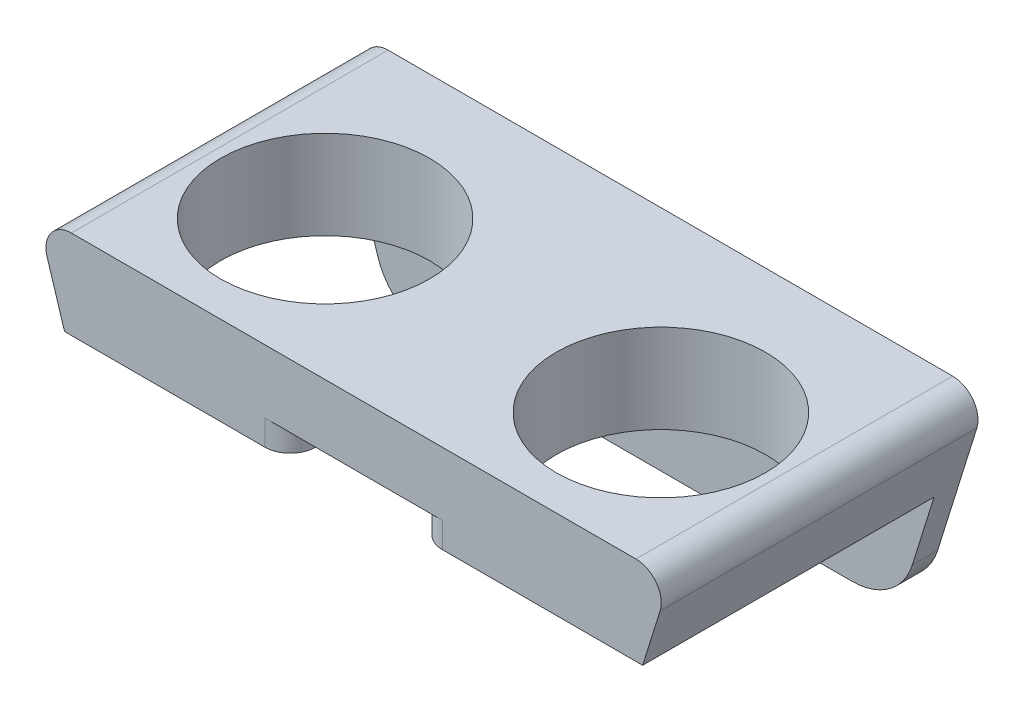
from build123d import *

# Parameters (mm, degrees)
SKETCH1_W               = 50
SKETCH1_H               = 24
SKETCH1_R               = 8.25
BOSS_EXTRUDE1_DEPTH     = 7
SKETCH2_W               = 12.5
SKETCH2_H               = 4.5
CUT_EXTRUDE1_DEPTH      = 4.022504106
SKETCH3_W               = 50
SKETCH3_H               = 16
SKETCH3_R               = 1.55
BOSS_EXTRUDE2_DEPTH     = 2
CUT_EXTRUDE2_DEPTH      = 25
CUT_EXTRUDE2_DEPTH_BACK = 3
FILLET1_R               = 5
FILLET2_R               = 2
SKETCH5_W               = 57.1125727
SKETCH5_H               = 23.157416517
CUT_EXTRUDE3_DEPTH      = 1
SKETCH6_W               = 10
SKETCH6_H               = 4
CUT_EXTRUDE4_DEPTH      = 2
FILLET3_R               = 1
FILLET4_R               = 2


with BuildPart() as part:
    # Sketch1 → Boss-Extrude1 (new body)
    with BuildSketch(Plane(origin=(0, 0, 0), x_dir=(1, 0, 0), z_dir=(0, 1, 0))):
        with Locations((-25, 12)):
            Rectangle(SKETCH1_W, SKETCH1_H)
        with Locations((-38.25, 12)):
            Circle(SKETCH1_R, mode=Mode.SUBTRACT)
        with Locations((-11.75, 12)):
            Circle(SKETCH1_R, mode=Mode.SUBTRACT)
    extrude(amount=BOSS_EXTRUDE1_DEPTH)

    # Sketch2 → Cut-Extrude1 (cut)
    with BuildSketch(Plane.XZ):
        with Locations((-25, -19.75)):
            Rectangle(SKETCH2_W, SKETCH2_H)
    extrude(amount=-CUT_EXTRUDE1_DEPTH, mode=Mode.SUBTRACT)

    # Sketch3 → Boss-Extrude2 (add)
    with BuildSketch(Plane(origin=(0, 0, -24), x_dir=(-1, 0, 0), z_dir=(0, 0, -1))):
        with Locations((25, -1)):
            Rectangle(SKETCH3_W, SKETCH3_H)
        with Locations((12.5, -6)):
            Circle(SKETCH3_R, mode=Mode.SUBTRACT)
        with Locations((37.5, -6)):
            Circle(SKETCH3_R, mode=Mode.SUBTRACT)
    extrude(amount=BOSS_EXTRUDE2_DEPTH)

    # Sketch4 → Cut-Extrude2 (cut, two sides)
    with BuildSketch(Plane.XY.offset(-24)) as cut_extrude2_sk:
        Polygon((-50, 7), (-45, -9), (-50, -9), align=None)
        Polygon((0, 7), (0, -9), (-5, -9), align=None)
    extrude(amount=CUT_EXTRUDE2_DEPTH, mode=Mode.SUBTRACT)
    extrude(cut_extrude2_sk.sketch, amount=-CUT_EXTRUDE2_DEPTH_BACK, mode=Mode.SUBTRACT)

    # Fillet1
    fillet1_edges = [part.edges().sort_by_distance(p)[0] for p in [
        (-45, -9, -25),
        (-5, -9, -25),
    ]]
    fillet(fillet1_edges, radius=FILLET1_R)

    # Fillet2
    fillet2_edges = [part.edges().sort_by_distance(p)[0] for p in [
        (0, 7, -13),
        (-50, 7, -13),
    ]]
    fillet(fillet2_edges, radius=FILLET2_R)

    # Sketch5 → Cut-Extrude3 (cut)
    with BuildSketch(Plane.XY):
        with Locations((-24.983022422, 0.513257307)):
            Rectangle(SKETCH5_W, SKETCH5_H)
    extrude(amount=-CUT_EXTRUDE3_DEPTH, mode=Mode.SUBTRACT)

    # Sketch6 → Cut-Extrude4 (cut)
    with BuildSketch(Plane.XZ):
        with Locations((-25, -3)):
            Rectangle(SKETCH6_W, SKETCH6_H)
    extrude(amount=-CUT_EXTRUDE4_DEPTH, mode=Mode.SUBTRACT)

    # Fillet3
    fillet3_edges = [part.edges().sort_by_distance(p)[0] for p in [
        (-30, 1, -5),
        (-20, 1, -5),
    ]]
    fillet(fillet3_edges, radius=FILLET3_R)

    # Fillet4
    fillet4_edges = [part.edges().sort_by_distance(p)[0] for p in [
        (-30, 1, -1),
        (-20, 1, -1),
    ]]
    fillet(fillet4_edges, radius=FILLET4_R)


solid = part.part
